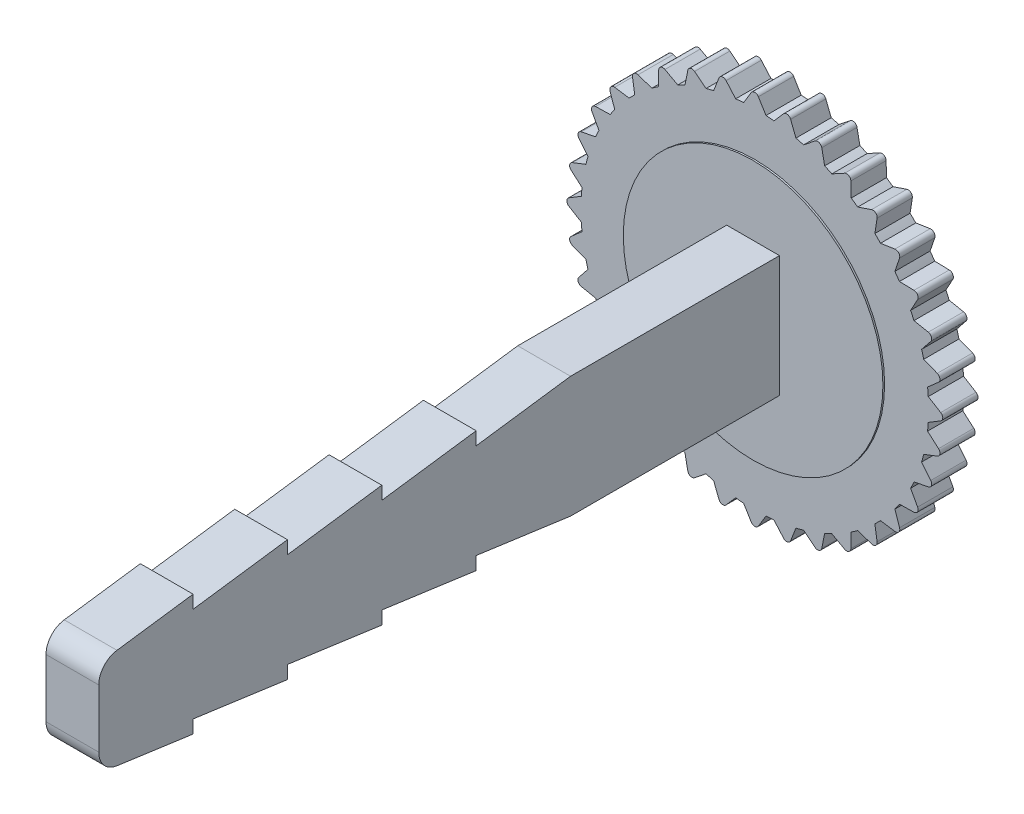
from build123d import *

# Parameters (mm, degrees)
BOSS_EXTRUDE1_DEPTH  = 1.67
SKETCH2_W            = 2.5
SKETCH2_H            = 5.74
BOSS_EXTRUDE8_DEPTH  = 32.33
CUT_EXTRUDE1_DEPTH   = 34
FILLET1_R            = 1
SKETCH4_R            = 6.15
CUT_EXTRUDE2_DEPTH   = 0.08
SKETCH5_R            = 6.15
BOSS_EXTRUDE9_DEPTH  = 0.08
SKETCH6_R            = 2.5
BOSS_EXTRUDE10_DEPTH = 0.19


with BuildPart() as part:
    # Sketch1 → Boss-Extrude1 (new body)
    with BuildSketch(Plane.XY):
        with BuildLine():
            Line((-0.53, 8.21792705), (-0.170918886, 8.808859205))
            ThreePointArc((-0.170918886, 8.808859205), (0, 8.905), (0.170918886, 8.808859205))
            Line((0.170918886, 8.808859205), (0.53, 8.21792705))
            ThreePointArc((0.53, 8.21792705), (0.717727542, 8.203663339), (0.905079947, 8.185111807))
            Line((0.905079947, 8.185111807), (1.361320104, 8.704712593))
            ThreePointArc((1.361320104, 8.704712593), (1.546337022, 8.769713041), (1.697964592, 8.645353087))
            Line((1.697964592, 8.645353087), (1.948976166, 8.001044738))
            ThreePointArc((1.948976166, 8.001044738), (2.131374836, 7.954399179), (2.312659498, 7.903596083))
            Line((2.312659498, 7.903596083), (2.852196072, 8.336077694))
            ThreePointArc((2.852196072, 8.336077694), (3.045689376, 8.367962788), (3.173418504, 8.219162291))
            Line((3.173418504, 8.219162291), (3.308733677, 7.541054731))
            ThreePointArc((3.308733677, 7.541054731), (3.480261385, 7.463444626), (3.649970061, 7.381933592))
            Line((3.649970061, 7.381933592), (4.256409506, 7.714155293))
            ThreePointArc((4.256409506, 7.714155293), (4.4525, 7.711956221), (4.5524497, 7.543236407))
            Line((4.5524497, 7.543236407), (4.567956989, 6.851933592))
            ThreePointArc((4.567956989, 6.851933592), (4.723401953, 6.745717085), (4.87637813, 6.635974784))
            Line((4.87637813, 6.635974784), (5.53129409, 6.857842186))
            ThreePointArc((5.53129409, 6.857842186), (5.724023664, 6.821625766), (5.793157015, 6.638113102))
            Line((5.793157015, 6.638113102), (5.68838524, 5.954619918))
            ThreePointArc((5.68838524, 5.954619918), (5.823024343, 5.823024343), (5.954619918, 5.68838524))
            Line((5.954619918, 5.68838524), (6.638113102, 5.793157015))
            ThreePointArc((6.638113102, 5.793157015), (6.821625766, 5.724023664), (6.857842186, 5.53129409))
            Line((6.857842186, 5.53129409), (6.635974784, 4.87637813))
            ThreePointArc((6.635974784, 4.87637813), (6.745717085, 4.723401953), (6.851933592, 4.567956989))
            Line((6.851933592, 4.567956989), (7.543236407, 4.5524497))
            ThreePointArc((7.543236407, 4.5524497), (7.711956221, 4.4525), (7.714155293, 4.256409506))
            Line((7.714155293, 4.256409506), (7.381933592, 3.649970061))
            ThreePointArc((7.381933592, 3.649970061), (7.463444626, 3.480261385), (7.541054731, 3.308733677))
            Line((7.541054731, 3.308733677), (8.219162291, 3.173418504))
            ThreePointArc((8.219162291, 3.173418504), (8.367962788, 3.045689376), (8.336077694, 2.852196072))
            Line((8.336077694, 2.852196072), (7.903596083, 2.312659498))
            ThreePointArc((7.903596083, 2.312659498), (7.954399179, 2.131374836), (8.001044738, 1.948976166))
            Line((8.001044738, 1.948976166), (8.645353087, 1.697964592))
            ThreePointArc((8.645353087, 1.697964592), (8.769713041, 1.546337022), (8.704712593, 1.361320104))
            Line((8.704712593, 1.361320104), (8.185111807, 0.905079947))
            ThreePointArc((8.185111807, 0.905079947), (8.203663339, 0.717727542), (8.21792705, 0.53))
            Line((8.21792705, 0.53), (8.808859205, 0.170918886))
            ThreePointArc((8.808859205, 0.170918886), (8.905, 0), (8.808859205, -0.170918886))
            Line((8.808859205, -0.170918886), (8.21792705, -0.53))
            ThreePointArc((8.21792705, -0.53), (8.203663339, -0.717727542), (8.185111807, -0.905079947))
            Line((8.185111807, -0.905079947), (8.704712593, -1.361320104))
            ThreePointArc((8.704712593, -1.361320104), (8.769713041, -1.546337022), (8.645353087, -1.697964592))
            Line((8.645353087, -1.697964592), (8.001044738, -1.948976166))
            ThreePointArc((8.001044738, -1.948976166), (7.954399179, -2.131374836), (7.903596083, -2.312659498))
            Line((7.903596083, -2.312659498), (8.336077694, -2.852196072))
            ThreePointArc((8.336077694, -2.852196072), (8.367962788, -3.045689376), (8.219162291, -3.173418504))
            Line((8.219162291, -3.173418504), (7.541054731, -3.308733677))
            ThreePointArc((7.541054731, -3.308733677), (7.463444626, -3.480261385), (7.381933592, -3.649970061))
            Line((7.381933592, -3.649970061), (7.714155293, -4.256409506))
            ThreePointArc((7.714155293, -4.256409506), (7.711956221, -4.4525), (7.543236407, -4.5524497))
            Line((7.543236407, -4.5524497), (6.851933592, -4.567956989))
            ThreePointArc((6.851933592, -4.567956989), (6.745717085, -4.723401953), (6.635974784, -4.87637813))
            Line((6.635974784, -4.87637813), (6.857842186, -5.53129409))
            ThreePointArc((6.857842186, -5.53129409), (6.821625766, -5.724023664), (6.638113102, -5.793157015))
            Line((6.638113102, -5.793157015), (5.954619918, -5.68838524))
            ThreePointArc((5.954619918, -5.68838524), (5.823024343, -5.823024343), (5.68838524, -5.954619918))
            Line((5.68838524, -5.954619918), (5.793157015, -6.638113102))
            ThreePointArc((5.793157015, -6.638113102), (5.724023664, -6.821625766), (5.53129409, -6.857842186))
            Line((5.53129409, -6.857842186), (4.87637813, -6.635974784))
            ThreePointArc((4.87637813, -6.635974784), (4.723401953, -6.745717085), (4.567956989, -6.851933592))
            Line((4.567956989, -6.851933592), (4.5524497, -7.543236407))
            ThreePointArc((4.5524497, -7.543236407), (4.4525, -7.711956221), (4.256409506, -7.714155293))
            Line((4.256409506, -7.714155293), (3.649970061, -7.381933592))
            ThreePointArc((3.649970061, -7.381933592), (3.480261385, -7.463444626), (3.308733677, -7.541054731))
            Line((3.308733677, -7.541054731), (3.173418504, -8.219162291))
            ThreePointArc((3.173418504, -8.219162291), (3.045689376, -8.367962788), (2.852196072, -8.336077694))
            Line((2.852196072, -8.336077694), (2.312659498, -7.903596083))
            ThreePointArc((2.312659498, -7.903596083), (2.131374836, -7.954399179), (1.948976166, -8.001044738))
            Line((1.948976166, -8.001044738), (1.697964592, -8.645353087))
            ThreePointArc((1.697964592, -8.645353087), (1.546337022, -8.769713041), (1.361320104, -8.704712593))
            Line((1.361320104, -8.704712593), (0.905079947, -8.185111807))
            ThreePointArc((0.905079947, -8.185111807), (0.717727542, -8.203663339), (0.53, -8.21792705))
            Line((0.53, -8.21792705), (0.170918886, -8.808859205))
            ThreePointArc((0.170918886, -8.808859205), (0, -8.905), (-0.170918886, -8.808859205))
            Line((-0.170918886, -8.808859205), (-0.53, -8.21792705))
            ThreePointArc((-0.53, -8.21792705), (-0.717727542, -8.203663339), (-0.905079947, -8.185111807))
            Line((-0.905079947, -8.185111807), (-1.361320104, -8.704712593))
            ThreePointArc((-1.361320104, -8.704712593), (-1.546337022, -8.769713041), (-1.697964592, -8.645353087))
            Line((-1.697964592, -8.645353087), (-1.948976166, -8.001044738))
            ThreePointArc((-1.948976166, -8.001044738), (-2.131374836, -7.954399179), (-2.312659498, -7.903596083))
            Line((-2.312659498, -7.903596083), (-2.852196072, -8.336077694))
            ThreePointArc((-2.852196072, -8.336077694), (-3.045689376, -8.367962788), (-3.173418504, -8.219162291))
            Line((-3.173418504, -8.219162291), (-3.308733677, -7.541054731))
            ThreePointArc((-3.308733677, -7.541054731), (-3.480261385, -7.463444626), (-3.649970061, -7.381933592))
            Line((-3.649970061, -7.381933592), (-4.256409506, -7.714155293))
            ThreePointArc((-4.256409506, -7.714155293), (-4.4525, -7.711956221), (-4.5524497, -7.543236407))
            Line((-4.5524497, -7.543236407), (-4.567956989, -6.851933592))
            ThreePointArc((-4.567956989, -6.851933592), (-4.723401953, -6.745717085), (-4.87637813, -6.635974784))
            Line((-4.87637813, -6.635974784), (-5.53129409, -6.857842186))
            ThreePointArc((-5.53129409, -6.857842186), (-5.724023664, -6.821625766), (-5.793157015, -6.638113102))
            Line((-5.793157015, -6.638113102), (-5.68838524, -5.954619918))
            ThreePointArc((-5.68838524, -5.954619918), (-5.823024343, -5.823024343), (-5.954619918, -5.68838524))
            Line((-5.954619918, -5.68838524), (-6.638113102, -5.793157015))
            ThreePointArc((-6.638113102, -5.793157015), (-6.821625766, -5.724023664), (-6.857842186, -5.53129409))
            Line((-6.857842186, -5.53129409), (-6.635974784, -4.87637813))
            ThreePointArc((-6.635974784, -4.87637813), (-6.745717085, -4.723401953), (-6.851933592, -4.567956989))
            Line((-6.851933592, -4.567956989), (-7.543236407, -4.5524497))
            ThreePointArc((-7.543236407, -4.5524497), (-7.711956221, -4.4525), (-7.714155293, -4.256409506))
            Line((-7.714155293, -4.256409506), (-7.381933592, -3.649970061))
            ThreePointArc((-7.381933592, -3.649970061), (-7.463444626, -3.480261385), (-7.541054731, -3.308733677))
            Line((-7.541054731, -3.308733677), (-8.219162291, -3.173418504))
            ThreePointArc((-8.219162291, -3.173418504), (-8.367962788, -3.045689376), (-8.336077694, -2.852196072))
            Line((-8.336077694, -2.852196072), (-7.903596083, -2.312659498))
            ThreePointArc((-7.903596083, -2.312659498), (-7.954399179, -2.131374836), (-8.001044738, -1.948976166))
            Line((-8.001044738, -1.948976166), (-8.645353087, -1.697964592))
            ThreePointArc((-8.645353087, -1.697964592), (-8.769713041, -1.546337022), (-8.704712593, -1.361320104))
            Line((-8.704712593, -1.361320104), (-8.185111807, -0.905079947))
            ThreePointArc((-8.185111807, -0.905079947), (-8.203663339, -0.717727542), (-8.21792705, -0.53))
            Line((-8.21792705, -0.53), (-8.808859205, -0.170918886))
            ThreePointArc((-8.808859205, -0.170918886), (-8.905, 0), (-8.808859205, 0.170918886))
            Line((-8.808859205, 0.170918886), (-8.21792705, 0.53))
            ThreePointArc((-8.21792705, 0.53), (-8.203663339, 0.717727542), (-8.185111807, 0.905079947))
            Line((-8.185111807, 0.905079947), (-8.704712593, 1.361320104))
            ThreePointArc((-8.704712593, 1.361320104), (-8.769713041, 1.546337022), (-8.645353087, 1.697964592))
            Line((-8.645353087, 1.697964592), (-8.001044738, 1.948976166))
            ThreePointArc((-8.001044738, 1.948976166), (-7.954399179, 2.131374836), (-7.903596083, 2.312659498))
            Line((-7.903596083, 2.312659498), (-8.336077694, 2.852196072))
            ThreePointArc((-8.336077694, 2.852196072), (-8.367962788, 3.045689376), (-8.219162291, 3.173418504))
            Line((-8.219162291, 3.173418504), (-7.541054731, 3.308733677))
            ThreePointArc((-7.541054731, 3.308733677), (-7.463444626, 3.480261385), (-7.381933592, 3.649970061))
            Line((-7.381933592, 3.649970061), (-7.714155293, 4.256409506))
            ThreePointArc((-7.714155293, 4.256409506), (-7.711956221, 4.4525), (-7.543236407, 4.5524497))
            Line((-7.543236407, 4.5524497), (-6.851933592, 4.567956989))
            ThreePointArc((-6.851933592, 4.567956989), (-6.745717085, 4.723401953), (-6.635974784, 4.87637813))
            Line((-6.635974784, 4.87637813), (-6.857842186, 5.53129409))
            ThreePointArc((-6.857842186, 5.53129409), (-6.821625766, 5.724023664), (-6.638113102, 5.793157015))
            Line((-6.638113102, 5.793157015), (-5.954619918, 5.68838524))
            ThreePointArc((-5.954619918, 5.68838524), (-5.823024343, 5.823024343), (-5.68838524, 5.954619918))
            Line((-5.68838524, 5.954619918), (-5.793157015, 6.638113102))
            ThreePointArc((-5.793157015, 6.638113102), (-5.724023664, 6.821625766), (-5.53129409, 6.857842186))
            Line((-5.53129409, 6.857842186), (-4.87637813, 6.635974784))
            ThreePointArc((-4.87637813, 6.635974784), (-4.723401953, 6.745717085), (-4.567956989, 6.851933592))
            Line((-4.567956989, 6.851933592), (-4.5524497, 7.543236407))
            ThreePointArc((-4.5524497, 7.543236407), (-4.4525, 7.711956221), (-4.256409506, 7.714155293))
            Line((-4.256409506, 7.714155293), (-3.649970061, 7.381933592))
            ThreePointArc((-3.649970061, 7.381933592), (-3.480261385, 7.463444626), (-3.308733677, 7.541054731))
            Line((-3.308733677, 7.541054731), (-3.173418504, 8.219162291))
            ThreePointArc((-3.173418504, 8.219162291), (-3.045689376, 8.367962788), (-2.852196072, 8.336077694))
            Line((-2.852196072, 8.336077694), (-2.312659498, 7.903596083))
            ThreePointArc((-2.312659498, 7.903596083), (-2.131374836, 7.954399179), (-1.948976166, 8.001044738))
            Line((-1.948976166, 8.001044738), (-1.697964592, 8.645353087))
            ThreePointArc((-1.697964592, 8.645353087), (-1.546337022, 8.769713041), (-1.361320104, 8.704712593))
            Line((-1.361320104, 8.704712593), (-0.905079947, 8.185111807))
            ThreePointArc((-0.905079947, 8.185111807), (-0.717727542, 8.203663339), (-0.53, 8.21792705))
        make_face()
    extrude(amount=BOSS_EXTRUDE1_DEPTH)

    # Sketch2 → Boss-Extrude8 (add)
    with BuildSketch(Plane.XY.offset(1.67)):
        Rectangle(SKETCH2_W, SKETCH2_H)
    extrude(amount=BOSS_EXTRUDE8_DEPTH)

    # Sketch3 → Cut-Extrude1 (cut)
    with BuildSketch(Plane(origin=(1.25, 0, 0), x_dir=(0, 0, -1), z_dir=(1, 0, 0))):
        Polygon((-29.53, -2.87), (-34, -2.25), (-34, -2.87), align=None)
        Polygon((-29.53, -2.25), (-29.53, -2.87), (-25.06, -2.87), align=None)
        Polygon((-25.06, -2.25), (-25.06, -2.87), (-20.59, -2.87), align=None)
        Polygon((-20.59, -2.25), (-20.59, -2.87), (-16.12, -2.87), align=None)
        Polygon((-16.12, -2.25), (-16.12, -2.87), (-11.65, -2.87), align=None)
        Polygon((-16.12, 2.25), (-11.65, 2.87), (-16.12, 2.87), align=None)
        Polygon((-20.59, 2.25), (-16.12, 2.87), (-20.59, 2.87), align=None)
        Polygon((-25.06, 2.25), (-20.59, 2.87), (-25.06, 2.87), align=None)
        Polygon((-29.53, 2.25), (-25.06, 2.87), (-29.53, 2.87), align=None)
        Polygon((-34, 2.25), (-29.53, 2.87), (-34, 2.87), align=None)
    extrude(amount=-CUT_EXTRUDE1_DEPTH, mode=Mode.SUBTRACT)

    # Fillet1
    fillet1_edges = [part.edges().sort_by_distance(p)[0] for p in [
        (0, -2.25, 34),
        (0, 2.25, 34),
    ]]
    fillet(fillet1_edges, radius=FILLET1_R)

    # Sketch4 → Cut-Extrude2 (cut)
    with BuildSketch(Plane(origin=(0, 0, 0), x_dir=(-1, 0, 0), z_dir=(0, 0, -1))):
        Circle(SKETCH4_R)
    extrude(amount=-CUT_EXTRUDE2_DEPTH, mode=Mode.SUBTRACT)

    # Sketch5 → Boss-Extrude9 (add)
    with BuildSketch(Plane.XY.offset(1.67)):
        Circle(SKETCH5_R)
    extrude(amount=BOSS_EXTRUDE9_DEPTH)

    # Sketch6 → Boss-Extrude10 (add)
    with BuildSketch(Plane(origin=(0, 0, 0.08), x_dir=(-1, 0, 0), z_dir=(0, 0, -1))):
        Circle(SKETCH6_R)
    extrude(amount=BOSS_EXTRUDE10_DEPTH)


solid = part.part
